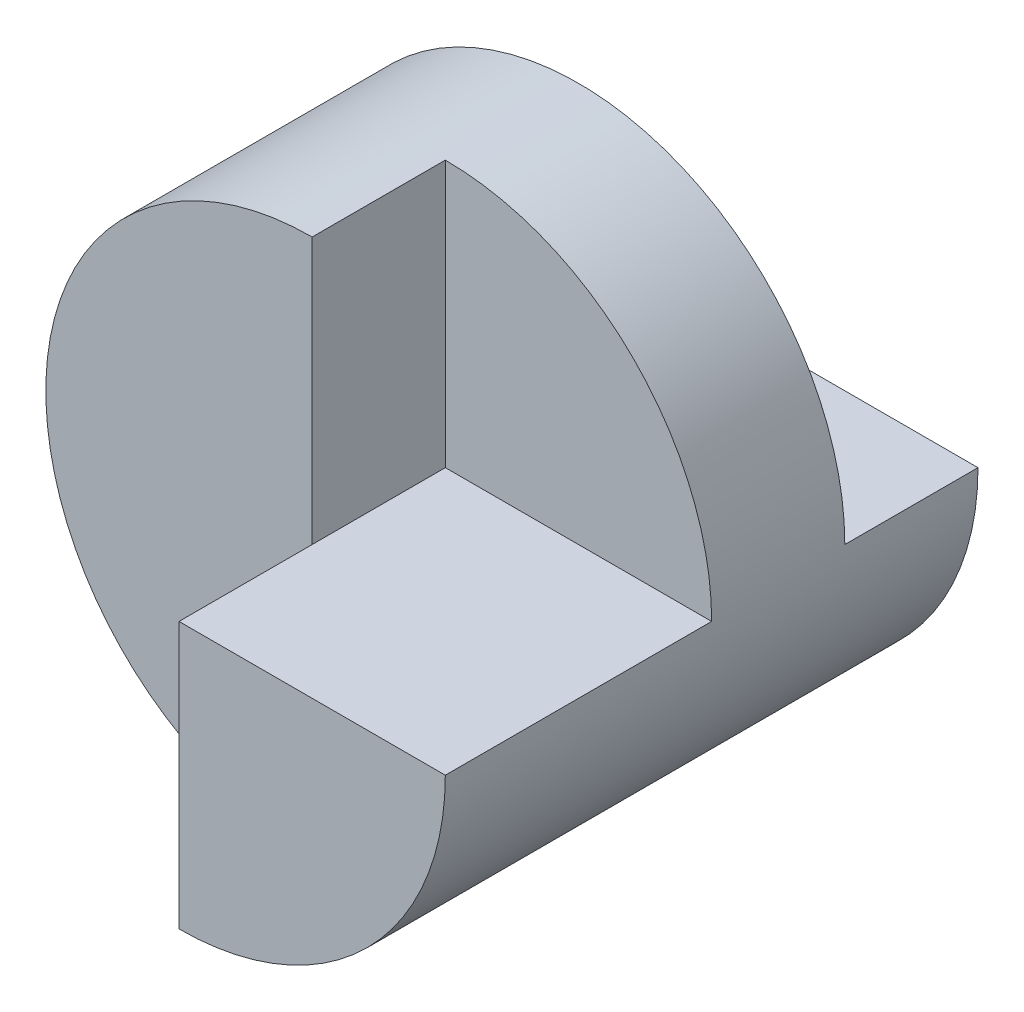
from build123d import *

# Parameters (mm, degrees)
SKETCH1_W           = 40
SKETCH1_H           = 40
BOSS_EXTRUDE1_DEPTH = 40
CUT_EXTRUDE1_DEPTH  = 40
SKETCH3_W           = 20
SKETCH3_H           = 10
CUT_EXTRUDE2_DEPTH  = 40
CUT_EXTRUDE3_DEPTH  = 20
CUT_EXTRUDE4_DEPTH  = 10


with BuildPart() as part:
    # Sketch1 → Boss-Extrude1 (new body)
    with BuildSketch(Plane.XY):
        with Locations((20, 20)):
            Rectangle(SKETCH1_W, SKETCH1_H)
    extrude(amount=BOSS_EXTRUDE1_DEPTH)

    # Sketch2 → Cut-Extrude1 (cut)
    with BuildSketch(Plane.XY.offset(40)):
        with BuildLine():
            Line((20, 40), (0, 40))
            Line((0, 40), (0, 20))
            ThreePointArc((0, 20), (5.857864376, 34.142135624), (20, 40))
        make_face()
        with BuildLine():
            ThreePointArc((20, 0), (5.857864376, 5.857864376), (0, 20))
            Line((0, 20), (0, 0))
            Line((0, 0), (20, 0))
        make_face()
        with BuildLine():
            Line((40, 0), (40, 20))
            ThreePointArc((40, 20), (34.142135624, 5.857864376), (20, 0))
            Line((20, 0), (40, 0))
        make_face()
        with BuildLine():
            Line((40, 40), (20, 40))
            ThreePointArc((20, 40), (34.142135624, 34.142135624), (40, 20))
            Line((40, 20), (40, 40))
        make_face()
    extrude(amount=-CUT_EXTRUDE1_DEPTH, mode=Mode.SUBTRACT)

    # Sketch3 → Cut-Extrude2 (cut)
    with BuildSketch(Plane(origin=(0, 0, 0), x_dir=(1, 0, 0), z_dir=(0, 1, 0))):
        with Locations((10, -35)):
            Rectangle(SKETCH3_W, SKETCH3_H)
    extrude(amount=CUT_EXTRUDE2_DEPTH, mode=Mode.SUBTRACT)

    # Sketch4 → Cut-Extrude3 (cut)
    with BuildSketch(Plane.XY.offset(40)):
        with BuildLine():
            Line((20, 20), (20, 40))
            ThreePointArc((20, 40), (34.142135624, 34.142135624), (40, 20))
            Line((40, 20), (20, 20))
        make_face()
    extrude(amount=-CUT_EXTRUDE3_DEPTH, mode=Mode.SUBTRACT)

    # Sketch5 → Cut-Extrude4 (cut)
    with BuildSketch(Plane(origin=(0, 0, 0), x_dir=(-1, 0, 0), z_dir=(0, 0, -1))):
        with BuildLine():
            Line((0, 20), (-40, 20))
            ThreePointArc((-40, 20), (-20, 40), (0, 20))
        make_face()
    extrude(amount=-CUT_EXTRUDE4_DEPTH, mode=Mode.SUBTRACT)


solid = part.part
